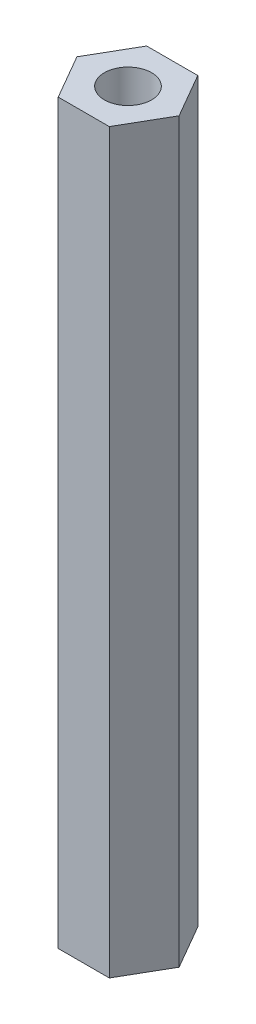
from build123d import *

# Parameters (mm, degrees)
EXTRUDE_1_DEPTH     = 50
SKETCH_2_R          = 1.6
CUT_EXTRUDE_1_DEPTH = 51


with BuildPart() as part:
    # 草图1 → 凸台-拉伸1 (new body)
    with BuildSketch(Plane(origin=(0, 0, 0), x_dir=(1, 0, 0), z_dir=(0, 1, 0))):
        Polygon((3.464101615, 0), (1.732050808, 3), (-1.732050808, 3), (-3.464101615, 0), (-1.732050808, -3), (1.732050808, -3), align=None)
    extrude(amount=EXTRUDE_1_DEPTH)

    # 草图2 → 切除-拉伸1 (cut, through all)
    with BuildSketch(Plane(origin=(0, 50, 0), x_dir=(1, 0, 0), z_dir=(0, 1, 0))):
        Circle(SKETCH_2_R)
    extrude(amount=-CUT_EXTRUDE_1_DEPTH, mode=Mode.SUBTRACT)


solid = part.part
